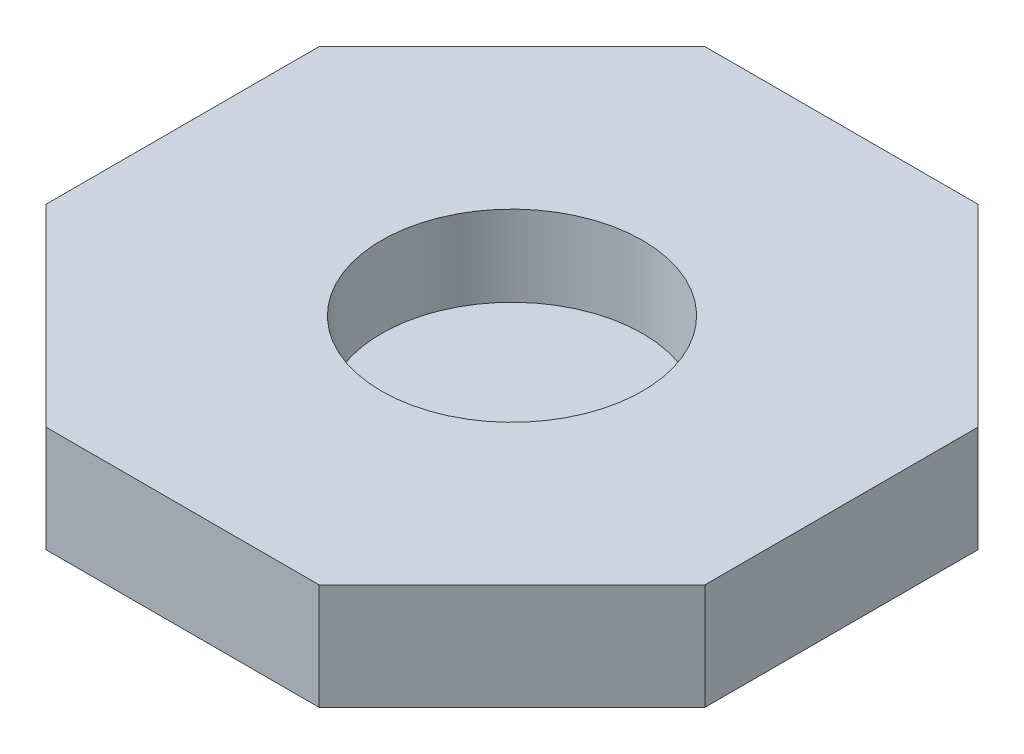
from build123d import *

# Parameters (mm, degrees)
EXTRUDE_1_DEPTH     = 5
CUT_EXTRUDE_1_DEPTH = 1
SKETCH_6_R          = 6.15
CUT_EXTRUDE_2_DEPTH = 3.8
SKETCH_8_R          = 4.15
SKETCH_8_R_2        = 3.15
EXTRUDE_4_DEPTH     = 7
SKETCH_9_R          = 5
SKETCH_9_R_2        = 4.15
EXTRUDE_5_DEPTH     = 2


with BuildPart() as part:
    # 스케치1 → 보스-돌출1 (new body)
    with BuildSketch(Plane(origin=(0, 0, 0), x_dir=(1, 0, 0), z_dir=(0, 1, 0))):
        Polygon((15.520132754, 6.428649477), (6.428649477, 15.520132754), (-6.428649477, 15.520132754), (-15.520132754, 6.428649477), (-15.520132754, -6.428649477), (-6.428649477, -15.520132754), (6.428649477, -15.520132754), (15.520132754, -6.428649477), align=None)
        Polygon((5.931593202, 14.320132754), (-5.931593202, 14.320132754), (-14.320132754, 5.931593202), (-14.320132754, -5.931593202), (-5.931593202, -14.320132754), (5.931593202, -14.320132754), (14.320132754, -5.931593202), (14.320132754, 5.931593202), align=None, mode=Mode.SUBTRACT)
        Polygon((14.320132754, 5.931593202), (5.931593202, 14.320132754), (-5.931593202, 14.320132754), (-14.320132754, 5.931593202), (-14.320132754, -5.931593202), (-5.931593202, -14.320132754), (5.931593202, -14.320132754), (14.320132754, -5.931593202), align=None)
    extrude(amount=EXTRUDE_1_DEPTH)

    # 스케치3 → 컷-돌출1 (cut)
    with BuildSketch(Plane.XZ):
        Polygon((5.931593202, -14.320132754), (14.320132754, -5.931593202), (14.320132754, 5.931593202), (5.931593202, 14.320132754), (-5.931593202, 14.320132754), (-14.320132754, 5.931593202), (-14.320132754, -5.931593202), (-5.931593202, -14.320132754), align=None)
        Polygon((5.434536927, -13.120132754), (13.120132754, -5.434536927), (13.120132754, 5.434536927), (5.434536927, 13.120132754), (-5.434536927, 13.120132754), (-13.120132754, 5.434536927), (-13.120132754, -5.434536927), (-5.434536927, -13.120132754), align=None, mode=Mode.SUBTRACT)
    extrude(amount=-CUT_EXTRUDE_1_DEPTH, mode=Mode.SUBTRACT)

    # 스케치6 → 컷-돌출2 (cut)
    with BuildSketch(Plane(origin=(0, 5, 0), x_dir=(1, 0, 0), z_dir=(0, 1, 0))):
        with Locations(Location((0, 0, 0), (0, 0, 270))):
            Circle(SKETCH_6_R)
    extrude(amount=-CUT_EXTRUDE_2_DEPTH, mode=Mode.SUBTRACT)

    # 스케치8 → 보스-돌출4 (add)
    with BuildSketch(Plane.XZ):
        with Locations(Location((0, 0, 0), (0, 0, 90))):
            Circle(SKETCH_8_R)
        with Locations(Location((0, 0, 0), (0, 0, 270))):
            Circle(SKETCH_8_R_2, mode=Mode.SUBTRACT)
    extrude(amount=EXTRUDE_4_DEPTH)

    # 스케치9 → 보스-돌출5 (add)
    with BuildSketch(Plane.XZ):
        with Locations(Location((0, 0, 0), (0, 0, 90))):
            Circle(SKETCH_9_R)
        with Locations(Location((0, 0, 0), (0, 0, 270))):
            Circle(SKETCH_9_R_2, mode=Mode.SUBTRACT)
    extrude(amount=EXTRUDE_5_DEPTH)


solid = part.part
